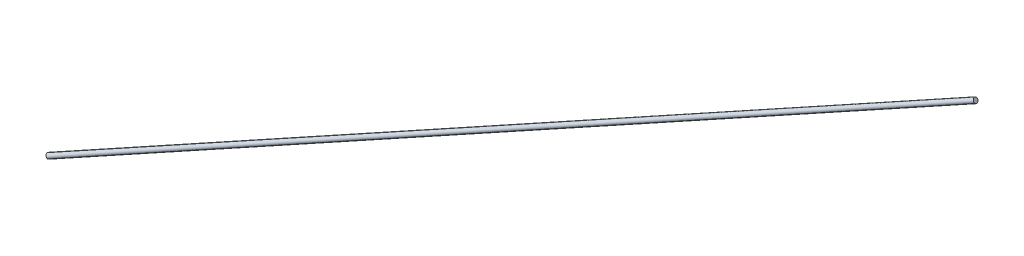
from build123d import *

# Parameters (mm, degrees)
SWEEP1_PROFILE_R = 5.08


with BuildPart() as part:
    # Sweep1: sweep along a curve in space
    with BuildLine() as sweep1_path:
        Line((1158.950801769, 2603.837106037, 1489.55455637), (-479.349198231, 1821.517106037, 1761.33455637))
    # Sweep1 profile (on start of the path) → Sweep1 (sweep)
    with BuildSketch(Plane(origin=(1158.950801769, 2603.837106037, 1489.55455637), x_dir=(0.430910861, -0.902394498, 0), z_dir=(-0.89245002, -0.42616218, 0.148049848))):
        Circle(SWEEP1_PROFILE_R)
    sweep(path=sweep1_path.line)


solid = part.part
